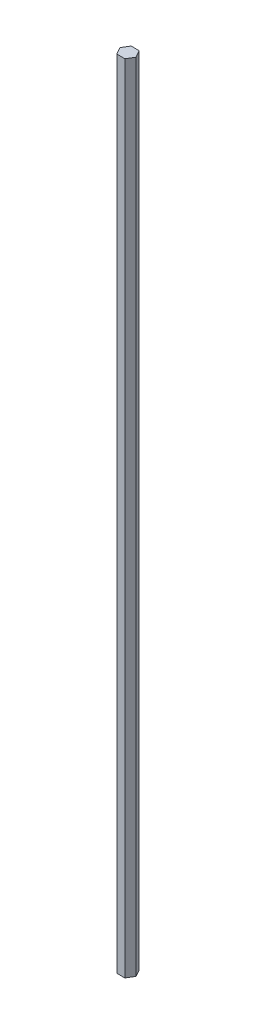
from build123d import *

# Parameters (mm, degrees)
BOSS_EXTRUDE1_DEPTH = 660.4


with BuildPart() as part:
    # Sketch1 → Boss-Extrude1 (new body)
    with BuildSketch(Plane(origin=(0, 0, 0), x_dir=(1, 0, 0), z_dir=(0, 1, 0))):
        Polygon((2.797786838, -5.299178619), (6.266844728, 0.486786425), (2.99058096, 6.384061207), (-3.754740699, 6.495370946), (-7.223798589, 0.709405902), (-3.947534821, -5.187868881), align=None)
    extrude(amount=BOSS_EXTRUDE1_DEPTH)


solid = part.part
